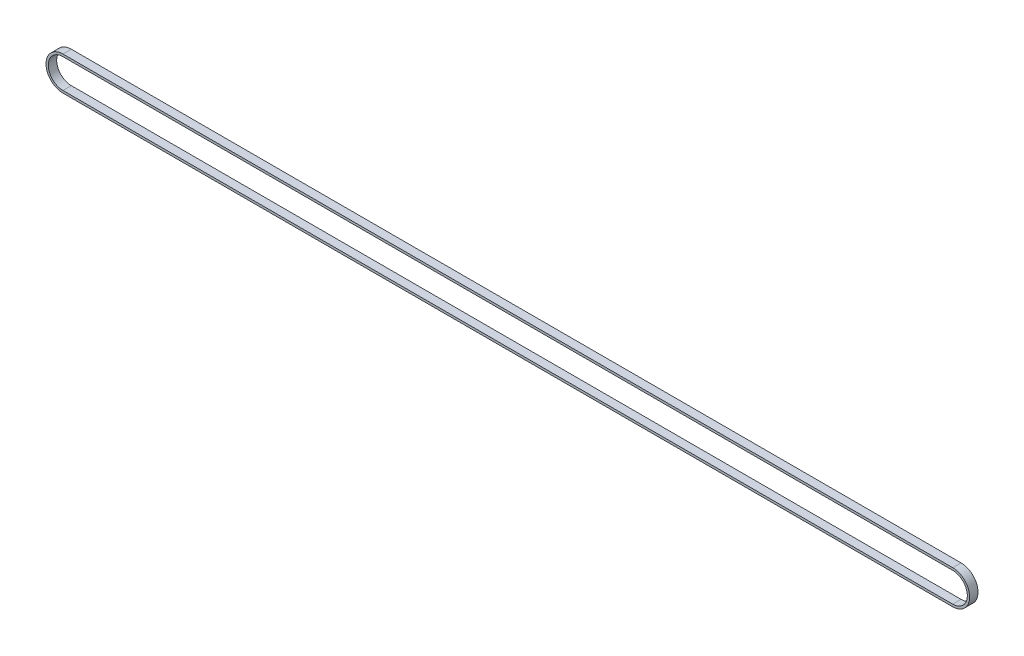
from build123d import *

# Parameters (mm, degrees)
EXTRUDE_THIN1_DEPTH = 2.5


with BuildPart() as part:
    # Sketch1 → Extrude-Thin1 (new body, symmetric)
    with BuildSketch(Plane.XY):
        with BuildLine():
            Line((532, -10.13), (0, -10.13))
            ThreePointArc((0, -10.13), (-10.13, 0), (0, 10.13))
            Line((0, 10.13), (532, 10.13))
            ThreePointArc((532, 10.13), (542.13, 0), (532, -10.13))
        make_face()
        with BuildLine():
            Line((532, -8.75), (0, -8.75))
            ThreePointArc((0, -8.75), (-8.75, 0), (0, 8.75))
            Line((0, 8.75), (532, 8.75))
            ThreePointArc((532, 8.75), (540.75, 0), (532, -8.75))
        make_face(mode=Mode.SUBTRACT)
    extrude(amount=EXTRUDE_THIN1_DEPTH, both=True)


solid = part.part
